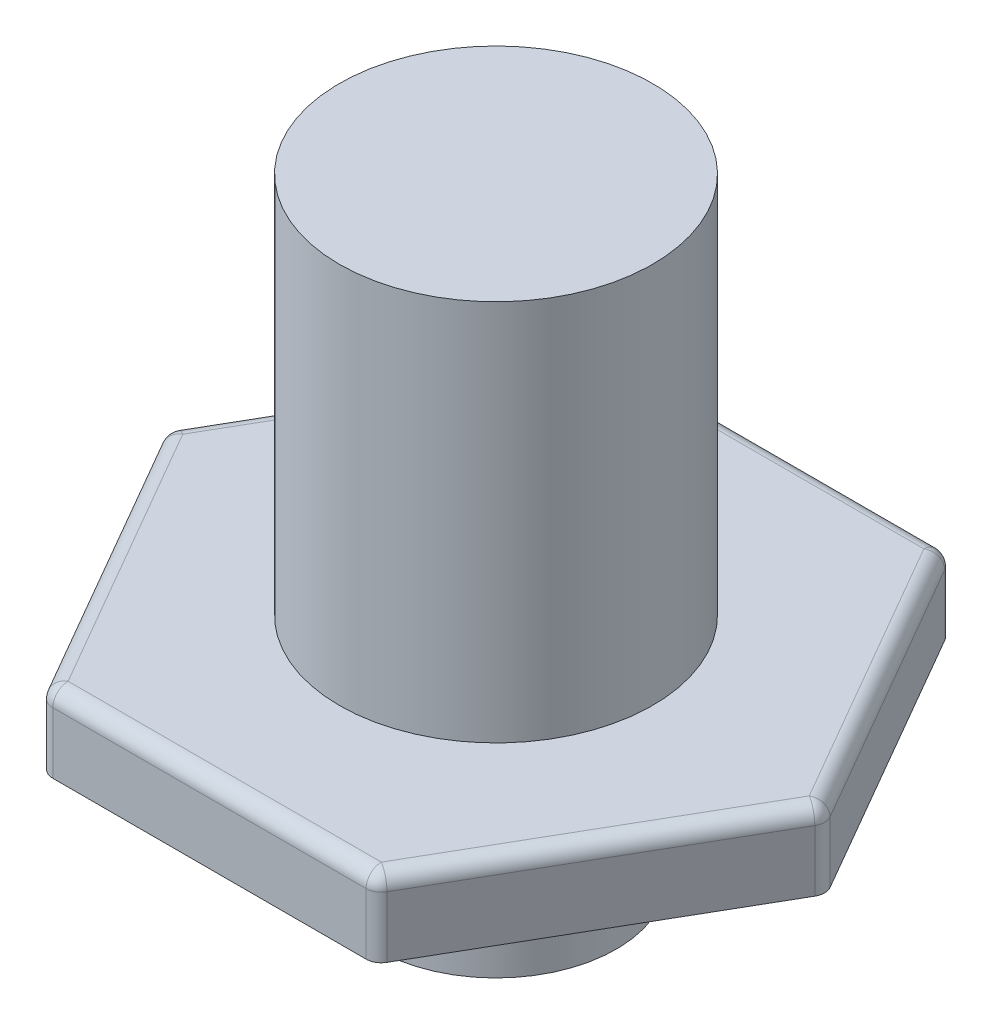
from build123d import *

# Parameters (mm, degrees)
BOSS_EXTRUDE1_DEPTH = 2.54
SKETCH2_R           = 5.207
BOSS_EXTRUDE2_DEPTH = 12.7
SKETCH6_R           = 4
BOSS_EXTRUDE3_DEPTH = 5.08
FILLET1_R           = 0.508


with BuildPart() as part:
    # Sketch1 → Boss-Extrude1 (new body)
    with BuildSketch(Plane(origin=(0, 0, 0), x_dir=(1, 0, 0), z_dir=(0, 1, 0))):
        Polygon((10.998522628, 0), (5.499261314, 9.525), (-5.499261314, 9.525), (-10.998522628, 0), (-5.499261314, -9.525), (5.499261314, -9.525), align=None)
    extrude(amount=BOSS_EXTRUDE1_DEPTH)

    # Sketch2 → Boss-Extrude2 (add)
    with BuildSketch(Plane(origin=(0, 2.54, 0), x_dir=(1, 0, 0), z_dir=(0, 1, 0))):
        Circle(SKETCH2_R)
    extrude(amount=BOSS_EXTRUDE2_DEPTH)

    # Sketch6 → Boss-Extrude3 (add)
    with BuildSketch(Plane(origin=(0, 0, 0), x_dir=(-1, 0, 0), z_dir=(0, -1, 0))):
        Circle(SKETCH6_R)
    extrude(amount=BOSS_EXTRUDE3_DEPTH)

    # Fillet1
    fillet1_edges = [part.edges().sort_by_distance(p)[0] for p in [
        (0, 2.54, -9.525),
        (5.499261314, 1.27, 9.525),
        (-5.499261314, 1.27, 9.525),
        (-10.998522628, 1.27, 0),
        (-5.499261314, 1.27, -9.525),
        (5.499261314, 1.27, -9.525),
        (10.998522628, 1.27, 0),
        (-8.248891971, 2.54, -4.7625),
        (-8.248891971, 2.54, 4.7625),
        (0, 2.54, 9.525),
        (8.248891971, 2.54, 4.7625),
        (8.248891971, 2.54, -4.7625),
    ]]
    fillet(fillet1_edges, radius=FILLET1_R)


solid = part.part
